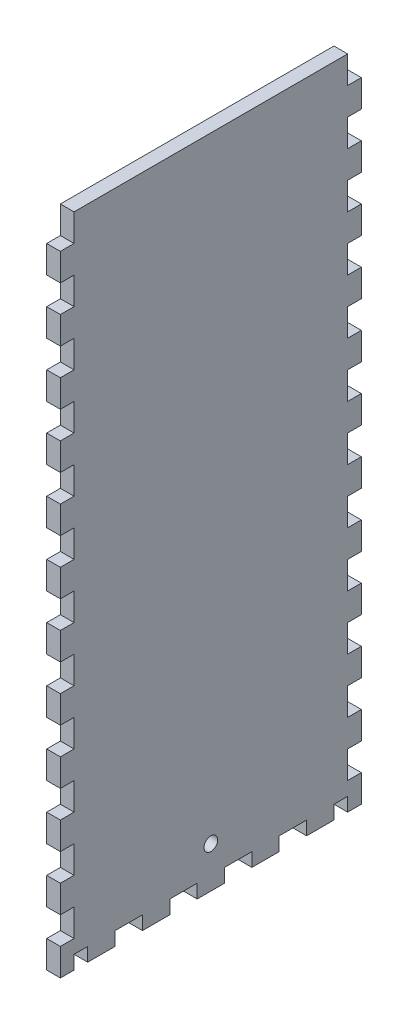
from build123d import *

# Parameters (mm, degrees)
SKETCH1_W              = 273.05
SKETCH1_H              = 139.7
BOSS_EXTRUDE1_DEPTH    = 6.35
SKETCH2_W              = 273.05
SKETCH2_H              = 139.7
SKETCH2_W_2            = 260.35
SKETCH2_H_2            = 127
BOSS_EXTRUDE2_DEPTH    = 298.45
SKETCH3_W              = 6.35
SKETCH3_H              = 16.933333333
SKETCH3_H_2            = 16.933333334
DOOR_SLOT_DEPTH        = 12.7
DOOR_GUIDE_HOLES_REACH = 361.617
SKETCH4_W              = 6.35
SKETCH4_H              = 15.875
LEVER_HOLES_W          = 9.652
LEVER_HOLES_H          = 6.35
LEVER_HOLES_W_2        = 6.35
CUT_EXTRUDE1_DEPTH     = 363.019620497
CUT_EXTRUDE2_REACH     = 417.137
SKETCH7_R              = 26.9875
CUT_EXTRUDE3_REACH     = 417.137
SKETCH8_R              = 3.175
SKETCH16_W             = 336.131526087
SKETCH16_H             = 315.233565403
CUT_EXTRUDE10_DEPTH    = 363.019620497
LEFT_RIGHT_W           = 6.35
LEFT_RIGHT_H           = 6.35
LEFT_RIGHT_W_2         = 12.7
LEFT_RIGHT_H_2         = 12.7
CUT_EXTRUDE11_DEPTH    = 313.765703043


with BuildPart() as part:
    # Sketch1 → Boss-Extrude1 (new body)
    with BuildSketch(Plane(origin=(0, 0, 0), x_dir=(1, 0, 0), z_dir=(0, 1, 0))):
        Rectangle(SKETCH1_W, SKETCH1_H)
    extrude(amount=BOSS_EXTRUDE1_DEPTH)

    # Sketch2 → Boss-Extrude2 (add)
    with BuildSketch(Plane(origin=(0, 6.35, 0), x_dir=(1, 0, 0), z_dir=(0, 1, 0))):
        Rectangle(SKETCH2_W, SKETCH2_H)
        Rectangle(SKETCH2_W_2, SKETCH2_H_2, mode=Mode.SUBTRACT)
    extrude(amount=BOSS_EXTRUDE2_DEPTH)

    # Sketch3 → Door Slot (cut)
    with BuildSketch(Plane.XY.offset(69.85)):
        with BuildLine():
            Line((-28.575, 283.21), (-28.575, 6.35))
            Line((-28.575, 6.35), (-21.971, 6.35))
            Line((-21.971, 6.35), (-21.971, 292.354))
            Line((-21.971, 292.354), (-41.529, 292.354))
            Line((-41.529, 292.354), (-41.529, 285.75))
            Line((-41.529, 285.75), (-31.115, 285.75))
            ThreePointArc((-31.115, 285.75), (-29.318948776, 285.006051224), (-28.575, 283.21))
        make_face()
        with Locations((-12.446, 80.433333334)):
            Rectangle(SKETCH3_W, SKETCH3_H)
        with Locations((-12.446, 50.8)):
            Rectangle(SKETCH3_W, SKETCH3_H_2)
        with Locations((-12.446, 21.166666667)):
            Rectangle(SKETCH3_W, SKETCH3_H)
    extrude(amount=-DOOR_SLOT_DEPTH, mode=Mode.SUBTRACT)

    # Sketch4 → Door Guide Holes (cut, up to next)
    with BuildSketch(Plane.XY.offset(-63.5), mode=Mode.PRIVATE) as door_guide_holes_sk1:
        with Locations((-44.704, 284.1625)):
            Rectangle(SKETCH4_W, SKETCH4_H)
    door_guide_holes_tool1 = extrude(door_guide_holes_sk1.sketch, amount=-DOOR_GUIDE_HOLES_REACH, mode=Mode.PRIVATE) & part.part
    # Sketch4 → Door Guide Holes (cut, up to next)
    with BuildSketch(Plane.XY.offset(-63.5), mode=Mode.PRIVATE) as door_guide_holes_sk2:
        with Locations((-44.704, 255.5875)):
            Rectangle(SKETCH4_W, SKETCH4_H)
    door_guide_holes_tool2 = extrude(door_guide_holes_sk2.sketch, amount=-DOOR_GUIDE_HOLES_REACH, mode=Mode.PRIVATE) & part.part
    # Sketch4 → Door Guide Holes (cut, up to next)
    with BuildSketch(Plane.XY.offset(-63.5), mode=Mode.PRIVATE) as door_guide_holes_sk3:
        with Locations((-44.704, 227.0125)):
            Rectangle(SKETCH4_W, SKETCH4_H)
    door_guide_holes_tool3 = extrude(door_guide_holes_sk3.sketch, amount=-DOOR_GUIDE_HOLES_REACH, mode=Mode.PRIVATE) & part.part
    # Sketch4 → Door Guide Holes (cut, up to next)
    with BuildSketch(Plane.XY.offset(-63.5), mode=Mode.PRIVATE) as door_guide_holes_sk4:
        with Locations((-44.704, 198.4375)):
            Rectangle(SKETCH4_W, SKETCH4_H)
    door_guide_holes_tool4 = extrude(door_guide_holes_sk4.sketch, amount=-DOOR_GUIDE_HOLES_REACH, mode=Mode.PRIVATE) & part.part
    # Sketch4 → Door Guide Holes (cut, up to next)
    with BuildSketch(Plane.XY.offset(-63.5), mode=Mode.PRIVATE) as door_guide_holes_sk5:
        with Locations((-44.704, 169.8625)):
            Rectangle(SKETCH4_W, SKETCH4_H)
    door_guide_holes_tool5 = extrude(door_guide_holes_sk5.sketch, amount=-DOOR_GUIDE_HOLES_REACH, mode=Mode.PRIVATE) & part.part
    # Sketch4 → Door Guide Holes (cut, up to next)
    with BuildSketch(Plane.XY.offset(-63.5), mode=Mode.PRIVATE) as door_guide_holes_sk6:
        with Locations((-44.704, 141.2875)):
            Rectangle(SKETCH4_W, SKETCH4_H)
    door_guide_holes_tool6 = extrude(door_guide_holes_sk6.sketch, amount=-DOOR_GUIDE_HOLES_REACH, mode=Mode.PRIVATE) & part.part
    # Sketch4 → Door Guide Holes (cut, up to next)
    with BuildSketch(Plane.XY.offset(-63.5), mode=Mode.PRIVATE) as door_guide_holes_sk7:
        with Locations((-44.704, 112.7125)):
            Rectangle(SKETCH4_W, SKETCH4_H)
    door_guide_holes_tool7 = extrude(door_guide_holes_sk7.sketch, amount=-DOOR_GUIDE_HOLES_REACH, mode=Mode.PRIVATE) & part.part
    # Sketch4 → Door Guide Holes (cut, up to next)
    with BuildSketch(Plane.XY.offset(-63.5), mode=Mode.PRIVATE) as door_guide_holes_sk8:
        with Locations((-44.704, 84.1375)):
            Rectangle(SKETCH4_W, SKETCH4_H)
    door_guide_holes_tool8 = extrude(door_guide_holes_sk8.sketch, amount=-DOOR_GUIDE_HOLES_REACH, mode=Mode.PRIVATE) & part.part
    # Sketch4 → Door Guide Holes (cut, up to next)
    with BuildSketch(Plane.XY.offset(-63.5), mode=Mode.PRIVATE) as door_guide_holes_sk9:
        with Locations((-44.704, 55.5625)):
            Rectangle(SKETCH4_W, SKETCH4_H)
    door_guide_holes_tool9 = extrude(door_guide_holes_sk9.sketch, amount=-DOOR_GUIDE_HOLES_REACH, mode=Mode.PRIVATE) & part.part
    # Sketch4 → Door Guide Holes (cut, up to next)
    with BuildSketch(Plane.XY.offset(-63.5), mode=Mode.PRIVATE) as door_guide_holes_sk10:
        with Locations((-44.704, 26.9875)):
            Rectangle(SKETCH4_W, SKETCH4_H)
    door_guide_holes_tool10 = extrude(door_guide_holes_sk10.sketch, amount=-DOOR_GUIDE_HOLES_REACH, mode=Mode.PRIVATE) & part.part
    door_guide_holes_1 = door_guide_holes_tool1.solids().sort_by_distance((-44.704, 284.1625, -63.5))[0]
    add(door_guide_holes_1, mode=Mode.SUBTRACT)
    door_guide_holes_2 = door_guide_holes_tool2.solids().sort_by_distance((-44.704, 255.5875, -63.5))[0]
    add(door_guide_holes_2, mode=Mode.SUBTRACT)
    door_guide_holes_3 = door_guide_holes_tool3.solids().sort_by_distance((-44.704, 227.0125, -63.5))[0]
    add(door_guide_holes_3, mode=Mode.SUBTRACT)
    door_guide_holes_4 = door_guide_holes_tool4.solids().sort_by_distance((-44.704, 198.4375, -63.5))[0]
    add(door_guide_holes_4, mode=Mode.SUBTRACT)
    door_guide_holes_5 = door_guide_holes_tool5.solids().sort_by_distance((-44.704, 169.8625, -63.5))[0]
    add(door_guide_holes_5, mode=Mode.SUBTRACT)
    door_guide_holes_6 = door_guide_holes_tool6.solids().sort_by_distance((-44.704, 141.2875, -63.5))[0]
    add(door_guide_holes_6, mode=Mode.SUBTRACT)
    door_guide_holes_7 = door_guide_holes_tool7.solids().sort_by_distance((-44.704, 112.7125, -63.5))[0]
    add(door_guide_holes_7, mode=Mode.SUBTRACT)
    door_guide_holes_8 = door_guide_holes_tool8.solids().sort_by_distance((-44.704, 84.1375, -63.5))[0]
    add(door_guide_holes_8, mode=Mode.SUBTRACT)
    door_guide_holes_9 = door_guide_holes_tool9.solids().sort_by_distance((-44.704, 55.5625, -63.5))[0]
    add(door_guide_holes_9, mode=Mode.SUBTRACT)
    door_guide_holes_10 = door_guide_holes_tool10.solids().sort_by_distance((-44.704, 26.9875, -63.5))[0]
    add(door_guide_holes_10, mode=Mode.SUBTRACT)
    door_guide_holes = door_guide_holes_1 + door_guide_holes_2 + door_guide_holes_3 + door_guide_holes_4 + door_guide_holes_5 + door_guide_holes_6 + door_guide_holes_7 + door_guide_holes_8 + door_guide_holes_9 + door_guide_holes_10  # Door Guide Holes as one shape, for the pattern or mirror that repeats it

    # Mirror1: Door Guide Holes across plane
    add(door_guide_holes.mirror(Plane.ZY.offset(31.75)), mode=Mode.SUBTRACT)

    # Lever Holes → Cut-Extrude1 (cut, through all)
    with BuildSketch(Plane.XY.offset(69.85)):
        with Locations((54.102, 28.575)):
            Rectangle(LEVER_HOLES_W, LEVER_HOLES_H)
        with Locations((39.3065, 15.875)):
            Rectangle(LEVER_HOLES_W_2, LEVER_HOLES_H)
        with Locations((68.8975, 15.875)):
            Rectangle(LEVER_HOLES_W_2, LEVER_HOLES_H)
    extrude(amount=-CUT_EXTRUDE1_DEPTH, mode=Mode.SUBTRACT)

    # Sketch7 → Cut-Extrude2 (cut, up to next)
    with BuildSketch(Plane(origin=(136.525, 0, 0), x_dir=(0, 0, -1), z_dir=(1, 0, 0)), mode=Mode.PRIVATE) as cut_extrude2_sk1:
        with Locations((0, 55.372)):
            Circle(SKETCH7_R)
    cut_extrude2_tool1 = extrude(cut_extrude2_sk1.sketch, amount=-CUT_EXTRUDE2_REACH, mode=Mode.PRIVATE) & part.part
    # Sketch7 → Cut-Extrude2 (cut, up to next)
    with BuildSketch(Plane(origin=(136.525, 0, 0), x_dir=(0, 0, -1), z_dir=(1, 0, 0)), mode=Mode.PRIVATE) as cut_extrude2_sk2:
        with BuildLine():
            Line((-37.211, 89.408), (-37.211, 92.583))
            Line((-37.211, 92.583), (-34.036, 92.583))
            ThreePointArc((-34.036, 92.583), (-39.45606403, 94.82806403), (-37.211, 89.408))
        make_face()
    cut_extrude2_tool2 = extrude(cut_extrude2_sk2.sketch, amount=-CUT_EXTRUDE2_REACH, mode=Mode.PRIVATE) & part.part
    # Sketch7 → Cut-Extrude2 (cut, up to next)
    with BuildSketch(Plane(origin=(136.525, 0, 0), x_dir=(0, 0, -1), z_dir=(1, 0, 0)), mode=Mode.PRIVATE) as cut_extrude2_sk3:
        with BuildLine():
            Line((-34.036, 92.583), (-37.211, 92.583))
            Line((-37.211, 92.583), (-37.211, 89.408))
            ThreePointArc((-37.211, 89.408), (-34.96593597, 90.33793597), (-34.036, 92.583))
        make_face()
    cut_extrude2_tool3 = extrude(cut_extrude2_sk3.sketch, amount=-CUT_EXTRUDE2_REACH, mode=Mode.PRIVATE) & part.part
    # Sketch7 → Cut-Extrude2 (cut, up to next)
    with BuildSketch(Plane(origin=(136.525, 0, 0), x_dir=(0, 0, -1), z_dir=(1, 0, 0)), mode=Mode.PRIVATE) as cut_extrude2_sk4:
        with BuildLine():
            Line((-37.211, 89.408), (-37.211, 92.583))
            Line((-37.211, 92.583), (-34.036, 92.583))
            ThreePointArc((-34.036, 92.583), (-39.45606403, 94.82806403), (-37.211, 89.408))
        make_face()
    cut_extrude2_tool4 = extrude(cut_extrude2_sk4.sketch, amount=-CUT_EXTRUDE2_REACH, mode=Mode.PRIVATE) & part.part
    # Sketch7 → Cut-Extrude2 (cut, up to next)
    with BuildSketch(Plane(origin=(136.525, 0, 0), x_dir=(0, 0, -1), z_dir=(1, 0, 0)), mode=Mode.PRIVATE) as cut_extrude2_sk5:
        with BuildLine():
            Line((-34.036, 92.583), (-37.211, 92.583))
            Line((-37.211, 92.583), (-37.211, 89.408))
            ThreePointArc((-37.211, 89.408), (-34.96593597, 90.33793597), (-34.036, 92.583))
        make_face()
    cut_extrude2_tool5 = extrude(cut_extrude2_sk5.sketch, amount=-CUT_EXTRUDE2_REACH, mode=Mode.PRIVATE) & part.part
    # Sketch7 → Cut-Extrude2 (cut, up to next)
    with BuildSketch(Plane(origin=(136.525, 0, 0), x_dir=(0, 0, -1), z_dir=(1, 0, 0)), mode=Mode.PRIVATE) as cut_extrude2_sk6:
        with BuildLine():
            ThreePointArc((40.386, 92.583), (37.211, 95.758), (34.036, 92.583))
            Line((34.036, 92.583), (37.211, 92.583))
            Line((37.211, 92.583), (37.211, 89.408))
            ThreePointArc((37.211, 89.408), (39.45606403, 90.33793597), (40.386, 92.583))
        make_face()
    cut_extrude2_tool6 = extrude(cut_extrude2_sk6.sketch, amount=-CUT_EXTRUDE2_REACH, mode=Mode.PRIVATE) & part.part
    # Sketch7 → Cut-Extrude2 (cut, up to next)
    with BuildSketch(Plane(origin=(136.525, 0, 0), x_dir=(0, 0, -1), z_dir=(1, 0, 0)), mode=Mode.PRIVATE) as cut_extrude2_sk7:
        with BuildLine():
            Line((37.211, 92.583), (34.036, 92.583))
            ThreePointArc((34.036, 92.583), (34.96593597, 90.33793597), (37.211, 89.408))
            Line((37.211, 89.408), (37.211, 92.583))
        make_face()
    cut_extrude2_tool7 = extrude(cut_extrude2_sk7.sketch, amount=-CUT_EXTRUDE2_REACH, mode=Mode.PRIVATE) & part.part
    # Sketch7 → Cut-Extrude2 (cut, up to next)
    with BuildSketch(Plane(origin=(136.525, 0, 0), x_dir=(0, 0, -1), z_dir=(1, 0, 0)), mode=Mode.PRIVATE) as cut_extrude2_sk8:
        with BuildLine():
            ThreePointArc((40.386, 92.583), (37.211, 95.758), (34.036, 92.583))
            Line((34.036, 92.583), (37.211, 92.583))
            Line((37.211, 92.583), (37.211, 89.408))
            ThreePointArc((37.211, 89.408), (39.45606403, 90.33793597), (40.386, 92.583))
        make_face()
    cut_extrude2_tool8 = extrude(cut_extrude2_sk8.sketch, amount=-CUT_EXTRUDE2_REACH, mode=Mode.PRIVATE) & part.part
    # Sketch7 → Cut-Extrude2 (cut, up to next)
    with BuildSketch(Plane(origin=(136.525, 0, 0), x_dir=(0, 0, -1), z_dir=(1, 0, 0)), mode=Mode.PRIVATE) as cut_extrude2_sk9:
        with BuildLine():
            Line((37.211, 92.583), (34.036, 92.583))
            ThreePointArc((34.036, 92.583), (34.96593597, 90.33793597), (37.211, 89.408))
            Line((37.211, 89.408), (37.211, 92.583))
        make_face()
    cut_extrude2_tool9 = extrude(cut_extrude2_sk9.sketch, amount=-CUT_EXTRUDE2_REACH, mode=Mode.PRIVATE) & part.part
    # Sketch7 → Cut-Extrude2 (cut, up to next)
    with BuildSketch(Plane(origin=(136.525, 0, 0), x_dir=(0, 0, -1), z_dir=(1, 0, 0)), mode=Mode.PRIVATE) as cut_extrude2_sk10:
        with BuildLine():
            ThreePointArc((-34.036, 18.161), (-34.96593597, 20.40606403), (-37.211, 21.336))
            Line((-37.211, 21.336), (-37.211, 18.161))
            Line((-37.211, 18.161), (-34.036, 18.161))
        make_face()
    cut_extrude2_tool10 = extrude(cut_extrude2_sk10.sketch, amount=-CUT_EXTRUDE2_REACH, mode=Mode.PRIVATE) & part.part
    # Sketch7 → Cut-Extrude2 (cut, up to next)
    with BuildSketch(Plane(origin=(136.525, 0, 0), x_dir=(0, 0, -1), z_dir=(1, 0, 0)), mode=Mode.PRIVATE) as cut_extrude2_sk11:
        with BuildLine():
            Line((-37.211, 18.161), (-37.211, 21.336))
            ThreePointArc((-37.211, 21.336), (-39.45606403, 15.91593597), (-34.036, 18.161))
            Line((-34.036, 18.161), (-37.211, 18.161))
        make_face()
    cut_extrude2_tool11 = extrude(cut_extrude2_sk11.sketch, amount=-CUT_EXTRUDE2_REACH, mode=Mode.PRIVATE) & part.part
    # Sketch7 → Cut-Extrude2 (cut, up to next)
    with BuildSketch(Plane(origin=(136.525, 0, 0), x_dir=(0, 0, -1), z_dir=(1, 0, 0)), mode=Mode.PRIVATE) as cut_extrude2_sk12:
        with BuildLine():
            ThreePointArc((-34.036, 18.161), (-34.96593597, 20.40606403), (-37.211, 21.336))
            Line((-37.211, 21.336), (-37.211, 18.161))
            Line((-37.211, 18.161), (-34.036, 18.161))
        make_face()
    cut_extrude2_tool12 = extrude(cut_extrude2_sk12.sketch, amount=-CUT_EXTRUDE2_REACH, mode=Mode.PRIVATE) & part.part
    # Sketch7 → Cut-Extrude2 (cut, up to next)
    with BuildSketch(Plane(origin=(136.525, 0, 0), x_dir=(0, 0, -1), z_dir=(1, 0, 0)), mode=Mode.PRIVATE) as cut_extrude2_sk13:
        with BuildLine():
            Line((-37.211, 18.161), (-37.211, 21.336))
            ThreePointArc((-37.211, 21.336), (-39.45606403, 15.91593597), (-34.036, 18.161))
            Line((-34.036, 18.161), (-37.211, 18.161))
        make_face()
    cut_extrude2_tool13 = extrude(cut_extrude2_sk13.sketch, amount=-CUT_EXTRUDE2_REACH, mode=Mode.PRIVATE) & part.part
    # Sketch7 → Cut-Extrude2 (cut, up to next)
    with BuildSketch(Plane(origin=(136.525, 0, 0), x_dir=(0, 0, -1), z_dir=(1, 0, 0)), mode=Mode.PRIVATE) as cut_extrude2_sk14:
        with BuildLine():
            ThreePointArc((40.386, 18.161), (39.45606403, 20.40606403), (37.211, 21.336))
            Line((37.211, 21.336), (37.211, 18.161))
            Line((37.211, 18.161), (34.036, 18.161))
            ThreePointArc((34.036, 18.161), (37.211, 14.986), (40.386, 18.161))
        make_face()
    cut_extrude2_tool14 = extrude(cut_extrude2_sk14.sketch, amount=-CUT_EXTRUDE2_REACH, mode=Mode.PRIVATE) & part.part
    # Sketch7 → Cut-Extrude2 (cut, up to next)
    with BuildSketch(Plane(origin=(136.525, 0, 0), x_dir=(0, 0, -1), z_dir=(1, 0, 0)), mode=Mode.PRIVATE) as cut_extrude2_sk15:
        with BuildLine():
            Line((37.211, 18.161), (37.211, 21.336))
            ThreePointArc((37.211, 21.336), (34.96593597, 20.40606403), (34.036, 18.161))
            Line((34.036, 18.161), (37.211, 18.161))
        make_face()
    cut_extrude2_tool15 = extrude(cut_extrude2_sk15.sketch, amount=-CUT_EXTRUDE2_REACH, mode=Mode.PRIVATE) & part.part
    # Sketch7 → Cut-Extrude2 (cut, up to next)
    with BuildSketch(Plane(origin=(136.525, 0, 0), x_dir=(0, 0, -1), z_dir=(1, 0, 0)), mode=Mode.PRIVATE) as cut_extrude2_sk16:
        with BuildLine():
            ThreePointArc((40.386, 18.161), (39.45606403, 20.40606403), (37.211, 21.336))
            Line((37.211, 21.336), (37.211, 18.161))
            Line((37.211, 18.161), (34.036, 18.161))
            ThreePointArc((34.036, 18.161), (37.211, 14.986), (40.386, 18.161))
        make_face()
    cut_extrude2_tool16 = extrude(cut_extrude2_sk16.sketch, amount=-CUT_EXTRUDE2_REACH, mode=Mode.PRIVATE) & part.part
    # Sketch7 → Cut-Extrude2 (cut, up to next)
    with BuildSketch(Plane(origin=(136.525, 0, 0), x_dir=(0, 0, -1), z_dir=(1, 0, 0)), mode=Mode.PRIVATE) as cut_extrude2_sk17:
        with BuildLine():
            Line((37.211, 18.161), (37.211, 21.336))
            ThreePointArc((37.211, 21.336), (34.96593597, 20.40606403), (34.036, 18.161))
            Line((34.036, 18.161), (37.211, 18.161))
        make_face()
    cut_extrude2_tool17 = extrude(cut_extrude2_sk17.sketch, amount=-CUT_EXTRUDE2_REACH, mode=Mode.PRIVATE) & part.part
    add(cut_extrude2_tool1.solids().sort_by_distance((136.525, 55.372, 0))[0], mode=Mode.SUBTRACT)
    add(cut_extrude2_tool2.solids().sort_by_distance((136.525, 93.032171, 37.660171))[0], mode=Mode.SUBTRACT)
    add(cut_extrude2_tool3.solids().sort_by_distance((136.525, 91.235488, 35.863488))[0], mode=Mode.SUBTRACT)
    add(cut_extrude2_tool4.solids().sort_by_distance((136.525, 93.032171, 37.660171))[0], mode=Mode.SUBTRACT)
    add(cut_extrude2_tool5.solids().sort_by_distance((136.525, 91.235488, 35.863488))[0], mode=Mode.SUBTRACT)
    add(cut_extrude2_tool6.solids().sort_by_distance((136.525, 93.032171, -37.660171))[0], mode=Mode.SUBTRACT)
    add(cut_extrude2_tool7.solids().sort_by_distance((136.525, 91.235488, -35.863488))[0], mode=Mode.SUBTRACT)
    add(cut_extrude2_tool8.solids().sort_by_distance((136.525, 93.032171, -37.660171))[0], mode=Mode.SUBTRACT)
    add(cut_extrude2_tool9.solids().sort_by_distance((136.525, 91.235488, -35.863488))[0], mode=Mode.SUBTRACT)
    add(cut_extrude2_tool10.solids().sort_by_distance((136.525, 19.508512, 35.863488))[0], mode=Mode.SUBTRACT)
    add(cut_extrude2_tool11.solids().sort_by_distance((136.525, 17.711829, 37.660171))[0], mode=Mode.SUBTRACT)
    add(cut_extrude2_tool12.solids().sort_by_distance((136.525, 19.508512, 35.863488))[0], mode=Mode.SUBTRACT)
    add(cut_extrude2_tool13.solids().sort_by_distance((136.525, 17.711829, 37.660171))[0], mode=Mode.SUBTRACT)
    add(cut_extrude2_tool14.solids().sort_by_distance((136.525, 17.711829, -37.660171))[0], mode=Mode.SUBTRACT)
    add(cut_extrude2_tool15.solids().sort_by_distance((136.525, 19.508512, -35.863488))[0], mode=Mode.SUBTRACT)
    add(cut_extrude2_tool16.solids().sort_by_distance((136.525, 17.711829, -37.660171))[0], mode=Mode.SUBTRACT)
    add(cut_extrude2_tool17.solids().sort_by_distance((136.525, 19.508512, -35.863488))[0], mode=Mode.SUBTRACT)

    # Sketch8 → Cut-Extrude3 (cut, up to next)
    with BuildSketch(Plane.ZY.offset(136.525), mode=Mode.PRIVATE) as cut_extrude3_sk1:
        with Locations((0, 19.05)):
            Circle(SKETCH8_R)
    cut_extrude3_tool1 = extrude(cut_extrude3_sk1.sketch, amount=-CUT_EXTRUDE3_REACH, mode=Mode.PRIVATE) & part.part
    add(cut_extrude3_tool1.solids().sort_by_distance((-136.525, 19.05, 0))[0], mode=Mode.SUBTRACT)

    # Sketch16 → Cut-Extrude10 (cut, through all)
    with BuildSketch(Plane.XY.offset(69.85)):
        with Locations((37.890763044, 147.183217299)):
            Rectangle(SKETCH16_W, SKETCH16_H)
    extrude(amount=-CUT_EXTRUDE10_DEPTH, mode=Mode.SUBTRACT)

    # Left/Right → Cut-Extrude11 (cut, through all)
    with BuildSketch(Plane.ZY.offset(136.525)):
        with Locations((60.325, 3.175)):
            Rectangle(LEFT_RIGHT_W, LEFT_RIGHT_H)
        with Locations((38.1, 3.175)):
            Rectangle(LEFT_RIGHT_W_2, LEFT_RIGHT_H)
        with Locations((66.675, 19.05)):
            Rectangle(LEFT_RIGHT_W, LEFT_RIGHT_H_2)
        with Locations((12.7, 3.175)):
            Rectangle(LEFT_RIGHT_W_2, LEFT_RIGHT_H)
        with Locations((66.675, 44.45)):
            Rectangle(LEFT_RIGHT_W, LEFT_RIGHT_H_2)
        with Locations((-12.7, 3.175)):
            Rectangle(LEFT_RIGHT_W_2, LEFT_RIGHT_H)
        with Locations((66.675, 69.85)):
            Rectangle(LEFT_RIGHT_W, LEFT_RIGHT_H_2)
        with Locations((-38.1, 3.175)):
            Rectangle(LEFT_RIGHT_W_2, LEFT_RIGHT_H)
        with Locations((66.675, 95.25)):
            Rectangle(LEFT_RIGHT_W, LEFT_RIGHT_H_2)
        with Locations((-60.325, 3.175)):
            Rectangle(LEFT_RIGHT_W, LEFT_RIGHT_H)
        with Locations((66.675, 120.65)):
            Rectangle(LEFT_RIGHT_W, LEFT_RIGHT_H_2)
        with Locations((-66.675, 19.05)):
            Rectangle(LEFT_RIGHT_W, LEFT_RIGHT_H_2)
        with Locations((66.675, 146.05)):
            Rectangle(LEFT_RIGHT_W, LEFT_RIGHT_H_2)
        with Locations((-66.675, 44.45)):
            Rectangle(LEFT_RIGHT_W, LEFT_RIGHT_H_2)
        with Locations((66.675, 171.45)):
            Rectangle(LEFT_RIGHT_W, LEFT_RIGHT_H_2)
        with Locations((-66.675, 69.85)):
            Rectangle(LEFT_RIGHT_W, LEFT_RIGHT_H_2)
        with Locations((66.675, 196.85)):
            Rectangle(LEFT_RIGHT_W, LEFT_RIGHT_H_2)
        with Locations((-66.675, 95.25)):
            Rectangle(LEFT_RIGHT_W, LEFT_RIGHT_H_2)
        with Locations((66.675, 222.25)):
            Rectangle(LEFT_RIGHT_W, LEFT_RIGHT_H_2)
        with Locations((-66.675, 120.65)):
            Rectangle(LEFT_RIGHT_W, LEFT_RIGHT_H_2)
        with Locations((66.675, 247.65)):
            Rectangle(LEFT_RIGHT_W, LEFT_RIGHT_H_2)
        with Locations((-66.675, 146.05)):
            Rectangle(LEFT_RIGHT_W, LEFT_RIGHT_H_2)
        with Locations((66.675, 273.05)):
            Rectangle(LEFT_RIGHT_W, LEFT_RIGHT_H_2)
        with Locations((-66.675, 171.45)):
            Rectangle(LEFT_RIGHT_W, LEFT_RIGHT_H_2)
        with Locations((66.675, 298.45)):
            Rectangle(LEFT_RIGHT_W, LEFT_RIGHT_H_2)
        with Locations((-66.675, 196.85)):
            Rectangle(LEFT_RIGHT_W, LEFT_RIGHT_H_2)
        with Locations((-66.675, 222.25)):
            Rectangle(LEFT_RIGHT_W, LEFT_RIGHT_H_2)
        with Locations((-66.675, 247.65)):
            Rectangle(LEFT_RIGHT_W, LEFT_RIGHT_H_2)
        with Locations((-66.675, 273.05)):
            Rectangle(LEFT_RIGHT_W, LEFT_RIGHT_H_2)
        with Locations((-66.675, 298.45)):
            Rectangle(LEFT_RIGHT_W, LEFT_RIGHT_H_2)
    extrude(amount=-CUT_EXTRUDE11_DEPTH, mode=Mode.SUBTRACT)


solid = part.part
